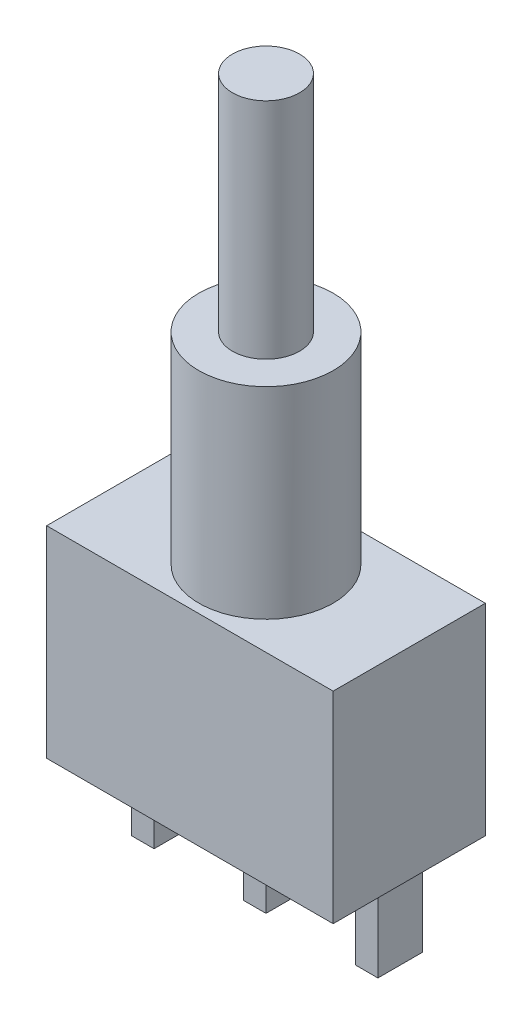
from build123d import *

# Parameters (mm, degrees)
ESQUISSE1_W        = 12.8
ESQUISSE1_H        = 9
BOSS_EXTRU_1_DEPTH = 6.8
ESQUISSE2_W        = 1
ESQUISSE2_H        = 2
BOSS_EXTRU_2_DEPTH = 4
ESQUISSE3_R        = 3
BOSS_EXTRU_3_DEPTH = 9
ESQUISSE4_R        = 1.5
BOSS_EXTRU_4_DEPTH = 10


with BuildPart() as part:
    # Esquisse1 → Boss.-Extru.1 (new body)
    with BuildSketch(Plane.XY):
        with Locations((6.4, 4.5)):
            Rectangle(ESQUISSE1_W, ESQUISSE1_H)
    extrude(amount=BOSS_EXTRU_1_DEPTH)

    # Esquisse2 → Boss.-Extru.2 (add)
    with BuildSketch(Plane.XZ):
        with Locations((1.4, 2.9)):
            Rectangle(ESQUISSE2_W, ESQUISSE2_H)
        with Locations((6.4, 2.9)):
            Rectangle(ESQUISSE2_W, ESQUISSE2_H)
        with Locations((11.4, 2.9)):
            Rectangle(ESQUISSE2_W, ESQUISSE2_H)
    extrude(amount=BOSS_EXTRU_2_DEPTH)

    # Esquisse3 → Boss.-Extru.3 (add)
    with BuildSketch(Plane(origin=(0, 9, 0), x_dir=(1, 0, 0), z_dir=(0, 1, 0))):
        with Locations((6.4, -3.4)):
            Circle(ESQUISSE3_R)
    extrude(amount=BOSS_EXTRU_3_DEPTH)

    # Esquisse4 → Boss.-Extru.4 (add)
    with BuildSketch(Plane(origin=(0, 18, 0), x_dir=(1, 0, 0), z_dir=(0, 1, 0))):
        with Locations((6.4, -3.4)):
            Circle(ESQUISSE4_R)
    extrude(amount=BOSS_EXTRU_4_DEPTH)


solid = part.part
